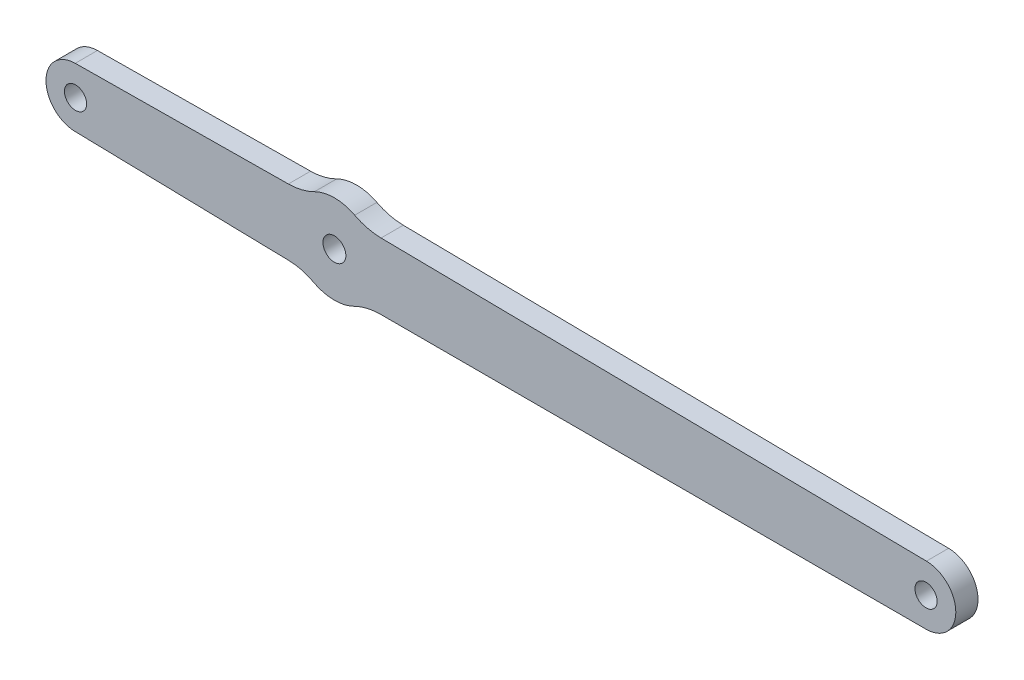
from build123d import *

# Parameters (mm, degrees)
MODEL_R             = 1.550000002
MODEL_R_2           = 1.499950001
BOSS_EXTRUDE1_DEPTH = 3


with BuildPart() as part:
    # Model → Boss-Extrude1 (new body)
    with BuildSketch(Plane.XY):
        with BuildLine():
            Line((32.97322454, 21.048024358), (61.783565293, 20.396552836))
            ThreePointArc((61.783565293, 20.396552836), (63.593806051, 20.160181577), (65.294277169, 19.495921878))
            ThreePointArc((65.294277169, 19.495921878), (68.013259801, 18.819198736), (70.743054605, 19.450895727))
            ThreePointArc((70.743054605, 19.450895727), (72.480596615, 20.079849108), (74.316088734, 20.293398335))
            Line((74.316088734, 20.293398335), (148.061464316, 20.29780157))
            ThreePointArc((148.061464316, 20.29780157), (152.087323917, 24.271545137), (148.113580351, 28.297404738))
            Line((148.113580351, 28.297404738), (74.374498298, 29.262702199))
            ThreePointArc((74.374498298, 29.262702199), (72.541936049, 29.500153645), (70.812729781, 30.151700471))
            ThreePointArc((70.812729781, 30.151700471), (68.091379164, 30.818941399), (65.363802325, 30.177626949))
            ThreePointArc((65.363802325, 30.177626949), (63.65169563, 29.548590215), (61.841711979, 29.322856457))
            Line((61.841711979, 29.322856457), (33.025330103, 29.046827594))
            ThreePointArc((33.025330103, 29.046827594), (29.063675601, 25.073063154), (32.97322454, 21.048024358))
        make_face()
        with Locations((68.062891797, 24.819037875)):
            Circle(MODEL_R, mode=Mode.SUBTRACT)
        with Locations((148.06117271, 24.297798301)):
            Circle(MODEL_R_2, mode=Mode.SUBTRACT)
        with Locations((33.063594348, 25.047007004)):
            Circle(MODEL_R_2, mode=Mode.SUBTRACT)
    extrude(amount=BOSS_EXTRUDE1_DEPTH)


solid = part.part
